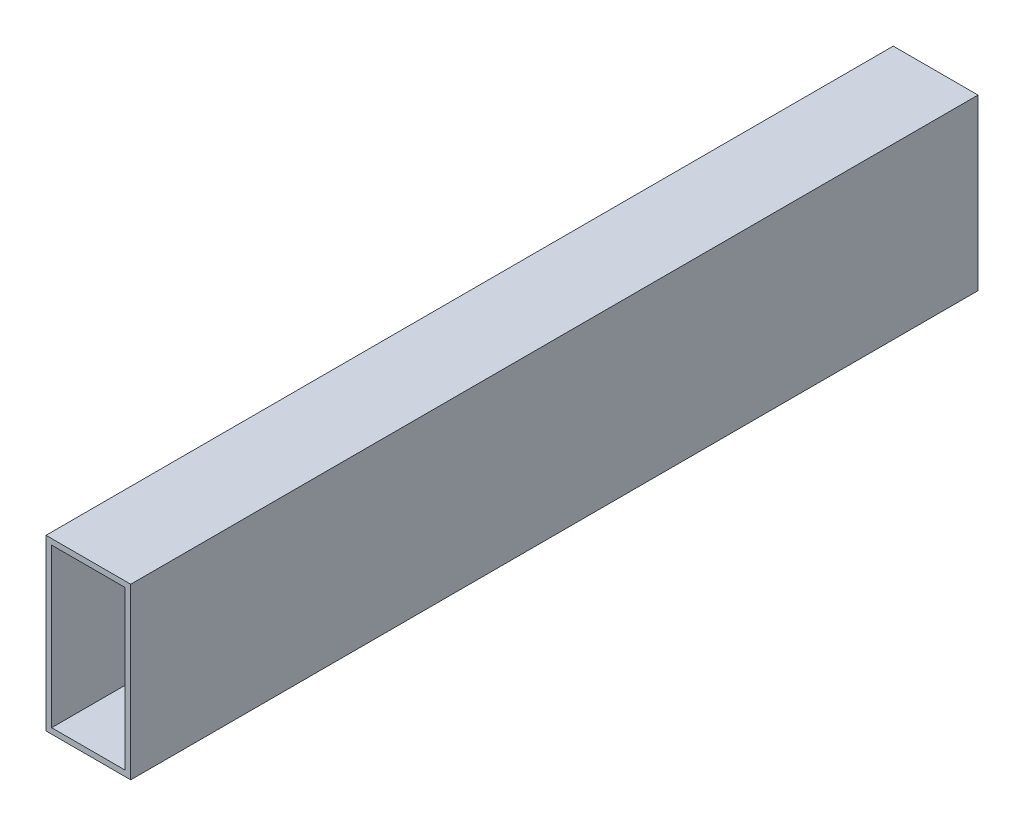
from build123d import *

# Parameters (mm, degrees)
SKETCH1_W   = 60
SKETCH1_H   = 120
SKETCH1_W_2 = 52
SKETCH1_H_2 = 112


with BuildPart() as part:
    # Sweep1: sweep along a curve in space
    with BuildLine() as sweep1_path:
        add(Edge.make_bspline(
            [(0, 0, -300), (0, 0, 300)],
            knots=[0, 0, 1, 1], degree=1))
    # Sketch1 → Sweep1 (sweep)
    with BuildSketch(Plane.XY):
        Rectangle(SKETCH1_W, SKETCH1_H)
        Rectangle(SKETCH1_W_2, SKETCH1_H_2, mode=Mode.SUBTRACT)
    sweep(path=sweep1_path.line)


solid = part.part
